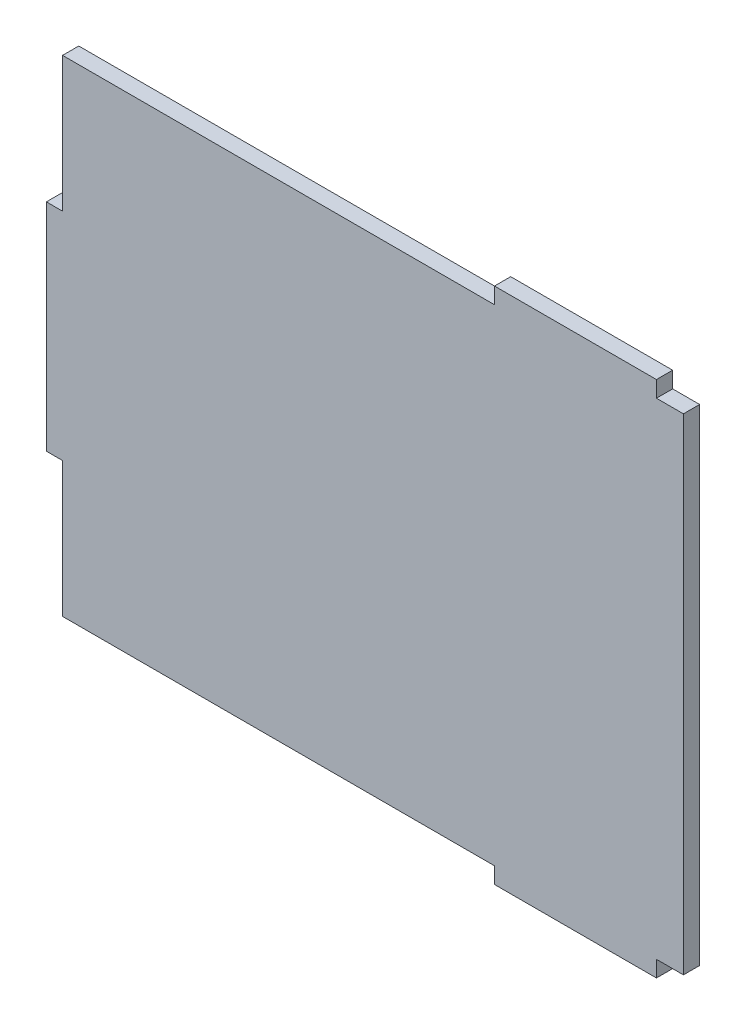
from build123d import *

# Parameters (mm, degrees)
BOSS_EXTRUDE1_DEPTH = 3


with BuildPart() as part:
    # Sketch1 → Boss-Extrude1 (new body)
    with BuildSketch(Plane.XY):
        Polygon((-57.5, -20), (-57.5, -45), (22.5, -45), (22.5, -48), (52.5, -48), (52.5, -45), (57.5, -45), (57.5, 45), (52.5, 45), (52.5, 48), (22.5, 48), (22.5, 45), (-57.5, 45), (-57.5, 20), (-60.5, 20), (-60.5, -20), align=None)
    extrude(amount=BOSS_EXTRUDE1_DEPTH)


solid = part.part
